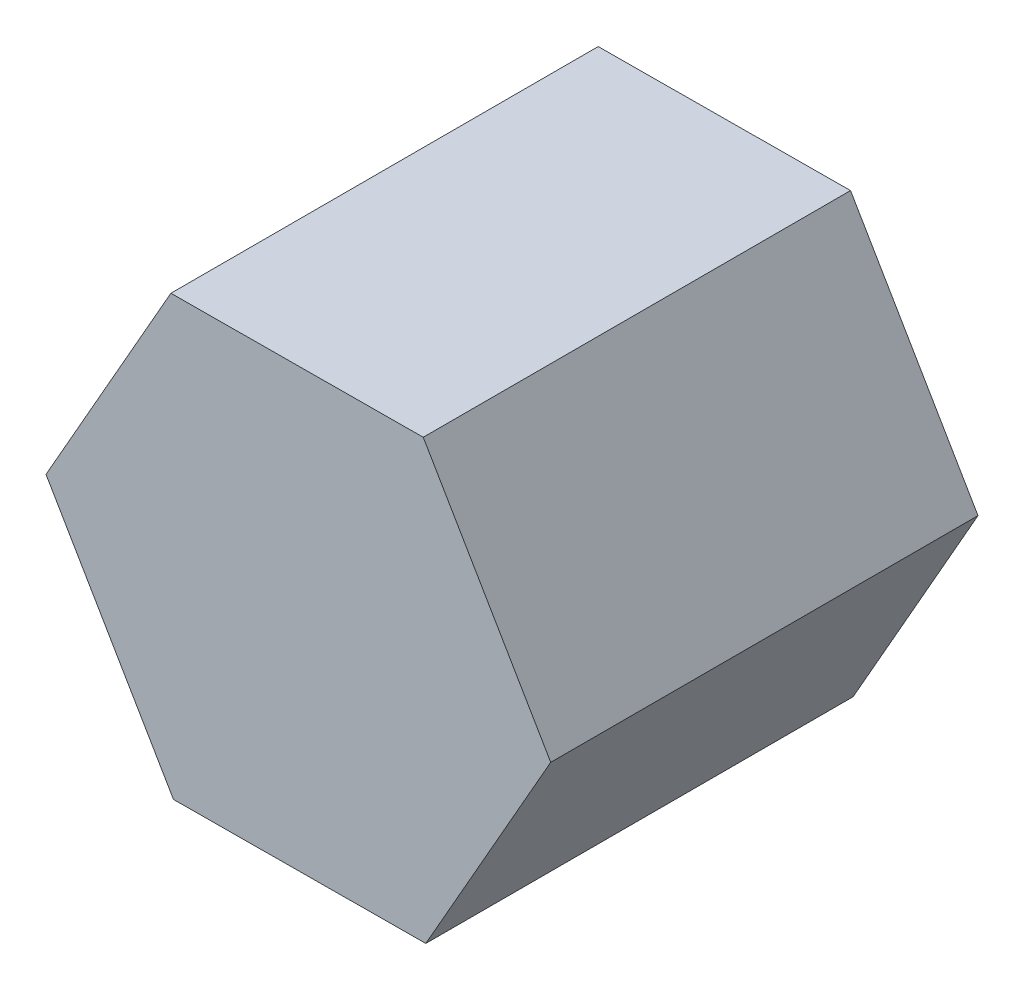
from build123d import *

# Parameters (mm, degrees)
ESTRUSIONE_ESTRUSIONE1_DEPTH = 160


with BuildPart() as part:
    # Schizzo1 → Estrusione-Estrusione1 (new body)
    with BuildSketch(Plane.XY):
        Polygon((-47.728459164, 81.561290977), (-94.498379534, -0.553412631), (-46.769920369, -82.114703608), (47.728459164, -81.561290977), (94.498379534, 0.553412631), (46.769920369, 82.114703608), align=None)
    extrude(amount=ESTRUSIONE_ESTRUSIONE1_DEPTH)


solid = part.part
